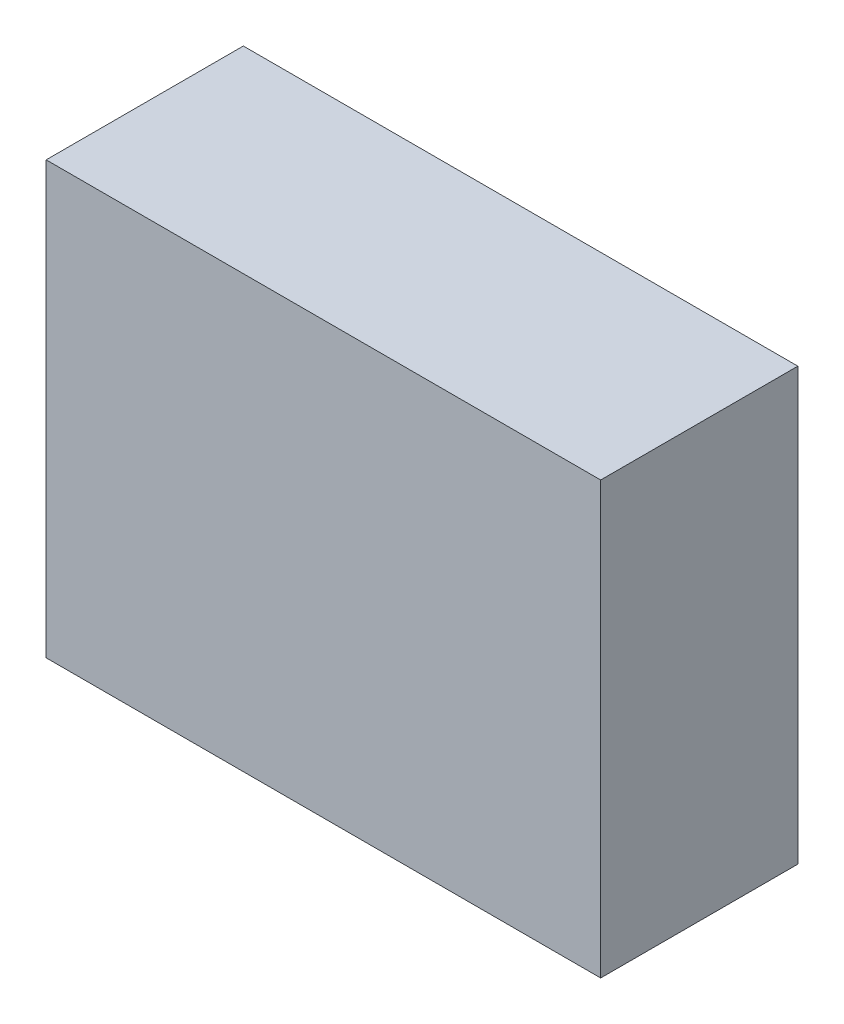
from build123d import *

# Parameters (mm, degrees)
SKETCH1_W           = 450
SKETCH1_H           = 350
BOSS_EXTRUDE1_DEPTH = 160


with BuildPart() as part:
    # Sketch1 → Boss-Extrude1 (new body)
    with BuildSketch(Plane.XY):
        Rectangle(SKETCH1_W, SKETCH1_H)
    extrude(amount=BOSS_EXTRUDE1_DEPTH)


solid = part.part
